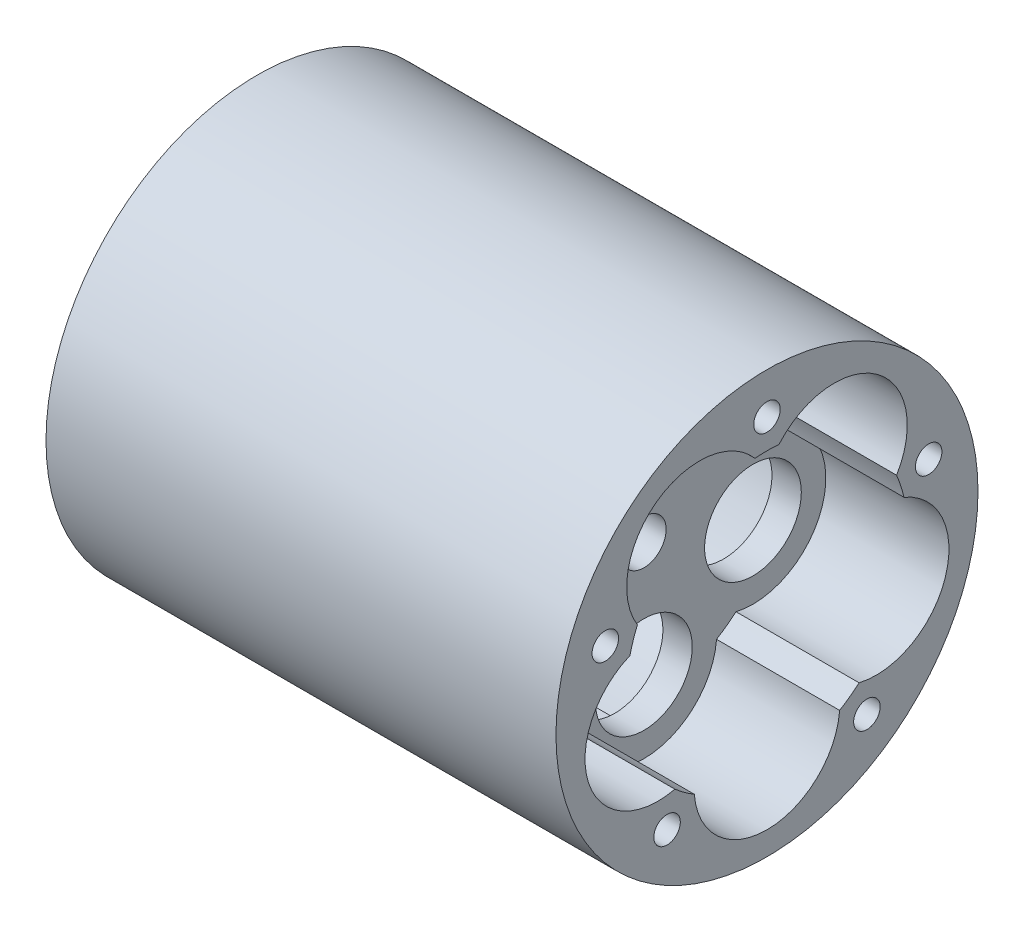
from build123d import *

# Parameters (mm, degrees)
SKETCH1_R                = 16
SKETCH1_R_2              = 4.125
BOSS_EXTRUDE1_DEPTH      = 2.5
SKETCH2_R                = 18
SKETCH2_R_2              = 16
BOSS_EXTRUDE2_DEPTH      = 10.5
BOSS_EXTRUDE2_DEPTH_BACK = 30
SKETCH3_R                = 18
BOSS_EXTRUDE3_DEPTH      = 3
SKETCH4_R                = 1.89865
CUT_EXTRUDE1_DEPTH       = 3
BOSS_EXTRUDE4_DEPTH      = 31
SKETCH6_R                = 0.75
CUT_EXTRUDE2_DEPTH       = 3
BOSS_EXTRUDE5_DEPTH      = 10.5
SKETCH8_R                = 1.1303
CUT_EXTRUDE3_DEPTH       = 23


with BuildPart() as part:
    # Sketch1 → Boss-Extrude1 (new body)
    with BuildSketch(Plane(origin=(0, 0, 0), x_dir=(0, 0, -1), z_dir=(1, 0, 0))):
        Circle(SKETCH1_R)
        with Locations((-5.75, 7.914196043)):
            Circle(SKETCH1_R_2, mode=Mode.SUBTRACT)
        with Locations((5.75, 7.914196043)):
            Circle(SKETCH1_R_2, mode=Mode.SUBTRACT)
        with Locations((9.303695435, -3.022953895)):
            Circle(SKETCH1_R_2, mode=Mode.SUBTRACT)
        with Locations((0, -9.782484296)):
            Circle(SKETCH1_R_2, mode=Mode.SUBTRACT)
        with Locations((-9.303695435, -3.022953895)):
            Circle(SKETCH1_R_2, mode=Mode.SUBTRACT)
    extrude(amount=BOSS_EXTRUDE1_DEPTH)

    # Sketch2 → Boss-Extrude2 (add, two sides)
    with BuildSketch(Plane(origin=(2.5, 0, 0), x_dir=(0, 0, -1), z_dir=(1, 0, 0))) as boss_extrude2_sk:
        Circle(SKETCH2_R)
        Circle(SKETCH2_R_2, mode=Mode.SUBTRACT)
    extrude(amount=BOSS_EXTRUDE2_DEPTH)
    extrude(boss_extrude2_sk.sketch, amount=-BOSS_EXTRUDE2_DEPTH_BACK)

    # Sketch3 → Boss-Extrude3 (add)
    with BuildSketch(Plane.ZY.offset(27.5)):
        Circle(SKETCH3_R)
    extrude(amount=BOSS_EXTRUDE3_DEPTH)

    # Sketch4 → Cut-Extrude1 (cut)
    with BuildSketch(Plane(origin=(2.5, 0, 0), x_dir=(0, 0, -1), z_dir=(1, 0, 0))):
        Circle(SKETCH4_R)
    extrude(amount=-CUT_EXTRUDE1_DEPTH, mode=Mode.SUBTRACT)

    # Sketch5 → Boss-Extrude4 (add)
    with BuildSketch(Plane(origin=(2.5, 0, 0), x_dir=(0, 0, -1), z_dir=(1, 0, 0))):
        Polygon((-0.75, -15), (-0.5, -14.75), (0.5, -14.75), (0.75, -15), (0.75, -16.25), (-0.75, -16.25), align=None)
    extrude(amount=-BOSS_EXTRUDE4_DEPTH)

    # Sketch6 → Cut-Extrude2 (cut)
    with BuildSketch(Plane(origin=(2.5, 0, 0), x_dir=(0, 0, -1), z_dir=(1, 0, 0))):
        with Locations((0, 5.5)):
            Circle(SKETCH6_R)
    extrude(amount=-CUT_EXTRUDE2_DEPTH, mode=Mode.SUBTRACT)

    # Sketch7 → Boss-Extrude5 (add)
    with BuildSketch(Plane(origin=(2.5, 0, 0), x_dir=(0, 0, -1), z_dir=(1, 0, 0))):
        with BuildLine():
            ThreePointArc((-9.404564054, 12.944271897), (-5.021788452, 14.088919475), (-1.025538841, 11.956097611))
            ThreePointArc((-1.025538841, 11.956097611), (0, 12), (1.025538841, 11.956097611))
            ThreePointArc((1.025538841, 11.956097611), (5.021788614, 14.088919494), (9.404564318, 12.944271706))
            ThreePointArc((9.404564318, 12.944271706), (1.63e-07, 16), (-9.404564054, 12.944271897))
        make_face()
        with BuildLine():
            ThreePointArc((-11.054015612, 4.669982746), (-11.847540705, 9.12972016), (-9.404564054, 12.944271897))
            ThreePointArc((-9.404564054, 12.944271897), (-15.216904236, 4.944271986), (-15.216904316, -4.944271739))
            ThreePointArc((-15.216904316, -4.944271739), (-14.951176606, -0.422288989), (-11.687833473, 2.719291951))
            ThreePointArc((-11.687833473, 2.719291951), (-11.412678196, 3.708203932), (-11.054015612, 4.669982746))
        make_face()
        with BuildLine():
            ThreePointArc((-7.857296202, -9.069889547), (-12.343971357, -8.446442057), (-15.216904316, -4.944271739))
            ThreePointArc((-15.216904316, -4.944271739), (-9.40456411, -12.944271857), (0, -16))
            ThreePointArc((0, -16), (-4.218546896, -14.349908473), (-6.1979395, -10.27548276))
            ThreePointArc((-6.1979395, -10.27548276), (-7.053423028, -9.708203932), (-7.857296202, -9.069889547))
        make_face()
        with BuildLine():
            ThreePointArc((6.1979395, -10.27548276), (4.218546896, -14.349908473), (0, -16))
            ThreePointArc((0, -16), (9.404563995, -12.944271941), (15.216904229, -4.944272009))
            ThreePointArc((15.216904229, -4.944272009), (12.343971234, -8.446442126), (7.857296202, -9.069889547))
            ThreePointArc((7.857296202, -9.069889547), (7.053423028, -9.708203932), (6.1979395, -10.27548276))
        make_face()
        with BuildLine():
            ThreePointArc((16, 0), (14.256104466, 7.263847841), (9.404564318, 12.944271706))
            ThreePointArc((9.404564318, 12.944271706), (11.847540737, 9.12972), (11.054015612, 4.669982746))
            ThreePointArc((11.054015612, 4.669982746), (11.412678196, 3.708203932), (11.687833473, 2.719291951))
            ThreePointArc((11.687833473, 2.719291951), (14.951176666, -0.422289118), (15.216904229, -4.944272009))
            ThreePointArc((15.216904229, -4.944272009), (15.803013441, -2.502951492), (16, 0))
        make_face()
    extrude(amount=BOSS_EXTRUDE5_DEPTH)

    # Sketch8 → Cut-Extrude3 (cut)
    with BuildSketch(Plane(origin=(13, 0, 0), x_dir=(0, 0, -1), z_dir=(1, 0, 0))):
        with Locations((0, 14.5)):
            Circle(SKETCH8_R)
        with Locations((13.790319486, 4.480746418)):
            Circle(SKETCH8_R)
        with Locations((8.522886158, -11.730746418)):
            Circle(SKETCH8_R)
        with Locations((-8.522886158, -11.730746418)):
            Circle(SKETCH8_R)
        with Locations((-13.790319486, 4.480746418)):
            Circle(SKETCH8_R)
    extrude(amount=-CUT_EXTRUDE3_DEPTH, mode=Mode.SUBTRACT)


solid = part.part
